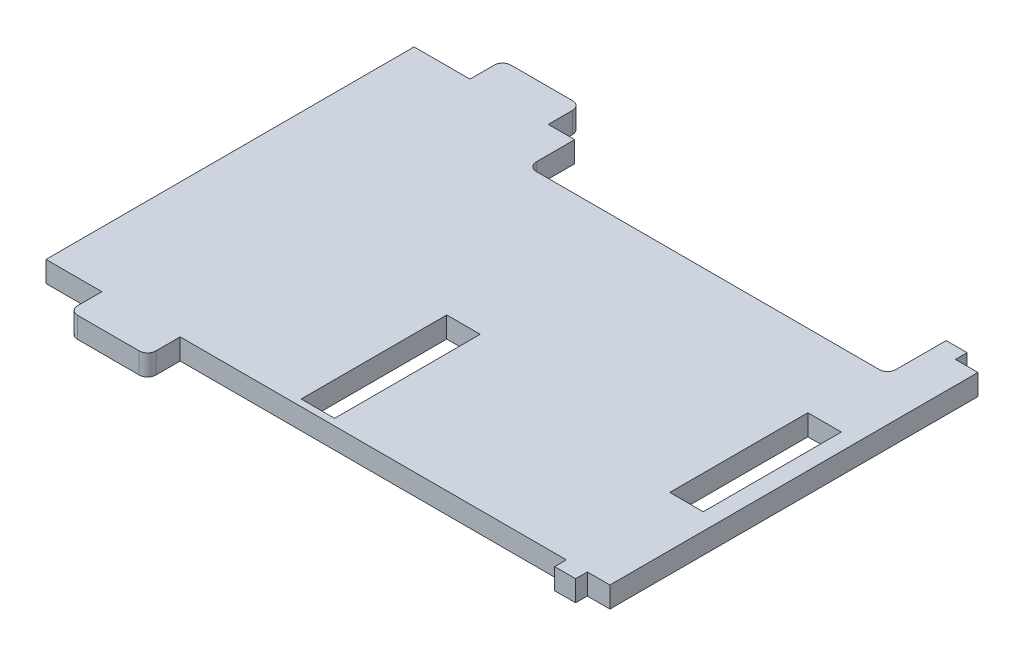
from build123d import *

# Parameters (mm, degrees)
SKETCH1_W           = 5.08
SKETCH1_H           = 20.955
SKETCH1_H_2         = 22.098
BOSS_EXTRUDE1_DEPTH = 3.175


with BuildPart() as part:
    # Sketch1 → Boss-Extrude1 (new body)
    with BuildSketch(Plane(origin=(0, 0, 0), x_dir=(1, 0, 0), z_dir=(0, 1, 0))):
        with BuildLine():
            Line((36.195, 27.94), (36.195, 22.098))
            ThreePointArc((36.195, 22.098), (35.823025612, 21.199974388), (34.925, 20.828))
            Line((34.925, 20.828), (-17.145, 20.828))
            ThreePointArc((-17.145, 20.828), (-18.043025612, 21.199974388), (-18.415, 22.098))
            Line((-18.415, 22.098), (-18.415, 27.94))
            Line((-18.415, 27.94), (-22.4282, 27.94))
            Line((-22.4282, 27.94), (-22.4282, 31.623))
            ThreePointArc((-22.4282, 31.623), (-22.800174388, 32.521025612), (-23.6982, 32.893))
            Line((-23.6982, 32.893), (-33.0454, 32.893))
            ThreePointArc((-33.0454, 32.893), (-33.943425612, 32.521025612), (-34.3154, 31.623))
            Line((-34.3154, 31.623), (-34.3154, 27.94))
            Line((-34.3154, 27.94), (-42.799, 27.94))
            Line((-42.799, 27.94), (-42.799, -27.94))
            Line((-42.799, -27.94), (-34.3154, -27.94))
            Line((-34.3154, -27.94), (-34.3154, -31.623))
            ThreePointArc((-34.3154, -31.623), (-33.943425612, -32.521025612), (-33.0454, -32.893))
            Line((-33.0454, -32.893), (-23.6982, -32.893))
            ThreePointArc((-23.6982, -32.893), (-22.800174388, -32.521025612), (-22.4282, -31.623))
            Line((-22.4282, -31.623), (-22.4282, -27.94))
            Line((-22.4282, -27.94), (36.195, -27.94))
            Line((36.195, -27.94), (36.195, -29.718))
            Line((36.195, -29.718), (39.37, -29.718))
            Line((39.37, -29.718), (39.37, -27.94))
            Line((39.37, -27.94), (42.799, -27.94))
            Line((42.799, -27.94), (42.799, 27.94))
            Line((42.799, 27.94), (39.37, 27.94))
            Line((39.37, 27.94), (39.37, 29.718))
            Line((39.37, 29.718), (36.195, 29.718))
            Line((36.195, 29.718), (36.195, 27.94))
        make_face()
        with Locations((37.719, -0.7493)):
            Rectangle(SKETCH1_W, SKETCH1_H, mode=Mode.SUBTRACT)
        with Locations((-2.54, -15.875)):
            Rectangle(SKETCH1_W, SKETCH1_H_2, mode=Mode.SUBTRACT)
    extrude(amount=BOSS_EXTRUDE1_DEPTH)


solid = part.part
